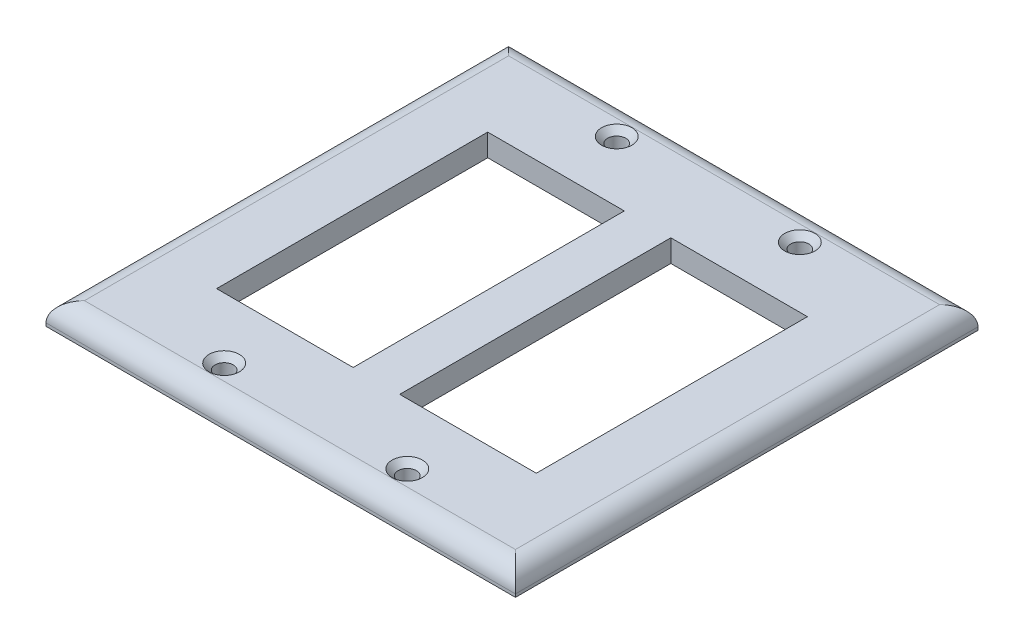
from build123d import *

# Parameters (mm, degrees)
SKETCH1_W           = 116
SKETCH1_H           = 114.3
SKETCH1_R           = 2.25
SKETCH1_W_2         = 33.75
SKETCH1_H_2         = 67
BOSS_EXTRUDE1_DEPTH = 5.5
FILLET1_R           = 4.75
CHAMFER1_SIZE       = 1.5


with BuildPart() as part:
    # Sketch1 → Boss-Extrude1 (new body)
    with BuildSketch(Plane(origin=(0, 0, 0), x_dir=(1, 0, 0), z_dir=(0, 1, 0))):
        with Locations((8.125405268, -27.177064496)):
            Rectangle(SKETCH1_W, SKETCH1_H)
        with Locations((-14.499594732, 21.322935504)):
            Circle(SKETCH1_R, mode=Mode.SUBTRACT)
        with Locations((-14.499594732, -75.677064496)):
            Circle(SKETCH1_R, mode=Mode.SUBTRACT)
        with Locations((30.750405268, -75.677064496)):
            Circle(SKETCH1_R, mode=Mode.SUBTRACT)
        with Locations((30.750405268, 21.322935504)):
            Circle(SKETCH1_R, mode=Mode.SUBTRACT)
        with Locations((-14.499594732, -27.177064496)):
            Rectangle(SKETCH1_W_2, SKETCH1_H_2, mode=Mode.SUBTRACT)
        with Locations((30.750405268, -27.177064496)):
            Rectangle(SKETCH1_W_2, SKETCH1_H_2, mode=Mode.SUBTRACT)
    extrude(amount=BOSS_EXTRUDE1_DEPTH)

    # Fillet1
    fillet1_edges = [part.edges().sort_by_distance(p)[0] for p in [
        (66.125405268, 5.5, 27.177064496),
        (8.125405268, 5.5, -29.972935504),
        (-49.874594732, 5.5, 27.177064496),
        (8.125405268, 5.5, 84.327064496),
    ]]
    fillet(fillet1_edges, radius=FILLET1_R)

    # Chamfer1
    chamfer1_edges = [part.edges().sort_by_distance(p)[0] for p in [
        (28.500405268, 5.5, 75.677064496),
        (-16.749594732, 5.5, 75.677064496),
        (-16.749594732, 5.5, -21.322935504),
        (28.500405268, 5.5, -21.322935504),
    ]]
    chamfer(chamfer1_edges, length=CHAMFER1_SIZE)


solid = part.part
